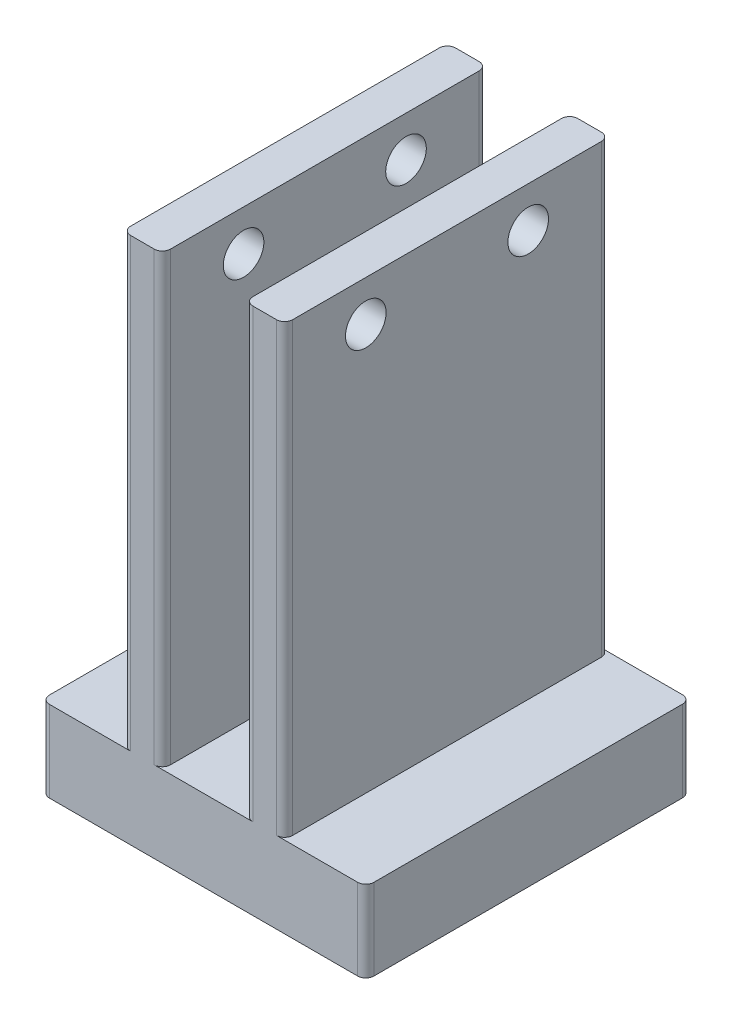
from build123d import *

# Parameters (mm, degrees)
SKETCH1_W             = 4.9
SKETCH1_H             = 40
BOSS_EXTRUDE1_DEPTH   = 55
BOSS_EXTRUDE1_2_DEPTH = 55
SKETCH2_W             = 19.95
SKETCH2_H             = 40
BOSS_EXTRUDE2_DEPTH   = 10
SKETCH3_R             = 2.5
CUT_EXTRUDE1_DEPTH    = 19.95
SKETCH5_W             = 40
SKETCH5_H             = 10
BOSS_EXTRUDE4_DEPTH   = 10
SKETCH6_W             = 40
SKETCH6_H             = 10
BOSS_EXTRUDE5_DEPTH   = 10
FILLET1_R             = 1


with BuildPart() as part:
    # Sketch1 → Boss-Extrude1 (new body)
    with BuildSketch(Plane(origin=(0, 0, 0), x_dir=(1, 0, 0), z_dir=(0, 1, 0))):
        with Locations((-10.05, 0)):
            Rectangle(SKETCH1_W, SKETCH1_H)
    extrude(amount=BOSS_EXTRUDE1_DEPTH)



with BuildPart() as body_2:
    # Sketch1 → Boss-Extrude1 2 (new body)
    with BuildSketch(Plane(origin=(0, 0, 0), x_dir=(1, 0, 0), z_dir=(0, 1, 0))):
        with Locations((5, 0)):
            Rectangle(SKETCH1_W, SKETCH1_H)
    extrude(amount=BOSS_EXTRUDE1_2_DEPTH)


with BuildPart() as part_1:
    add(part.part)

    add(body_2.part)  # Boss-Extrude2 merges body 2
    # Sketch2 → Boss-Extrude2 (add)
    with BuildSketch(Plane.XZ):
        with Locations((-2.525, 0)):
            Rectangle(SKETCH2_W, SKETCH2_H)
    extrude(amount=BOSS_EXTRUDE2_DEPTH)

    # Sketch3 → Cut-Extrude1 (cut)
    with BuildSketch(Plane.ZY.offset(12.5)):
        with Locations((-10, 50)):
            Circle(SKETCH3_R)
        with Locations((10, 50)):
            Circle(SKETCH3_R)
    extrude(amount=-CUT_EXTRUDE1_DEPTH, mode=Mode.SUBTRACT)

    # Sketch5 → Boss-Extrude4 (add)
    with BuildSketch(Plane.ZY.offset(12.5)):
        with Locations((0, -5)):
            Rectangle(SKETCH5_W, SKETCH5_H)
    extrude(amount=BOSS_EXTRUDE4_DEPTH)

    # Sketch6 → Boss-Extrude5 (add)
    with BuildSketch(Plane(origin=(7.45, 0, 0), x_dir=(0, 0, -1), z_dir=(1, 0, 0))):
        with Locations((0, -5)):
            Rectangle(SKETCH6_W, SKETCH6_H)
    extrude(amount=BOSS_EXTRUDE5_DEPTH)

    # Fillet1
    fillet1_edges = [part_1.edges().sort_by_distance(p)[0] for p in [
        (2.55, 27.5, -20),
        (2.55, 27.5, 20),
        (-22.5, -5, -20),
        (-22.5, -5, 20),
        (-12.5, 27.5, -20),
        (7.45, 27.5, -20),
        (7.45, 27.5, 20),
        (-7.6, 27.5, -20),
        (-7.6, 27.5, 20),
        (17.45, -5, 20),
        (-12.5, 27.5, 20),
        (17.45, -5, -20),
    ]]
    fillet(fillet1_edges, radius=FILLET1_R)


solid = part_1.part
